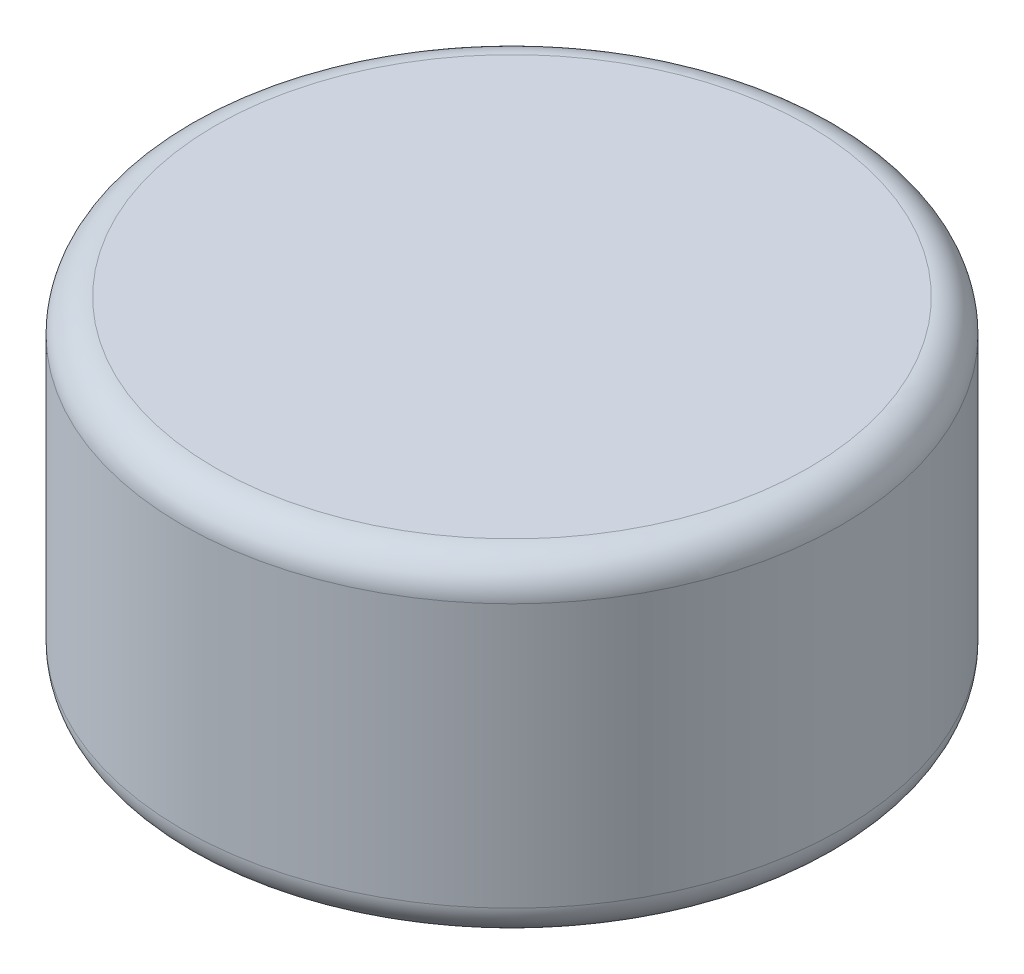
from build123d import *

# Parameters (mm, degrees)
SKETCH_2_R      = 2
EXTRUDE_1_DEPTH = 1
FILLET_1_R      = 0.2


with BuildPart() as part:
    # 草图2 → 凸台-拉伸1 (new body, symmetric)
    with BuildSketch(Plane(origin=(0, 0, 0), x_dir=(1, 0, 0), z_dir=(0, 1, 0))):
        Circle(SKETCH_2_R)
    extrude(amount=EXTRUDE_1_DEPTH, both=True)

    # 圆角1
    fillet_1_edges = [part.edges().sort_by_distance(p)[0] for p in [
        (-2, -1, 0),
        (-2, 1, 0),
    ]]
    fillet(fillet_1_edges, radius=FILLET_1_R)


solid = part.part
